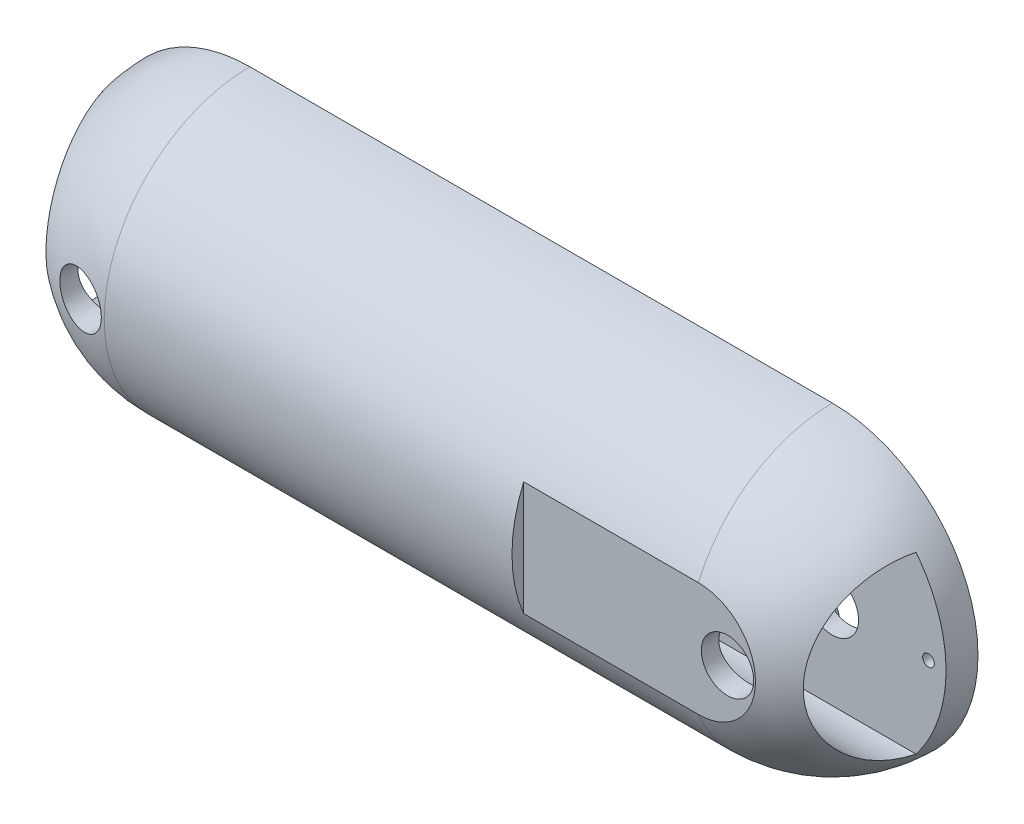
from build123d import *

# Parameters (mm, degrees)
REVOLVE1_ANGLE          = 180
SKETCH7_R               = 4.5
CUT_EXTRUDE2_DEPTH      = 26
CUT_EXTRUDE5_DEPTH      = 26
CUT_EXTRUDE5_DEPTH_BACK = 126
SKETCH12_W              = 5
SKETCH12_H              = 50
CUT_EXTRUDE6_DEPTH      = 20
CUT_EXTRUDE6_DEPTH_BACK = 30
CUT_EXTRUDE7_START      = -5
CUT_EXTRUDE7_DEPTH      = 2
SKETCH14_R              = 1
CUT_EXTRUDE8_DEPTH      = 5


with BuildPart() as part:
    # Sketch5 → Revolve1 (revolve)
    with BuildSketch(Plane.XY):
        with BuildLine():
            Line((0, 0), (-100, 0))
            Line((-100, 0), (-125, 0))
            ThreePointArc((-125, 0), (-117.67766953, 17.67766953), (-100, 25))
            Line((-100, 25), (0, 25))
            ThreePointArc((0, 25), (17.67766953, 17.67766953), (25, 0))
            Line((25, 0), (0, 0))
        make_face()
    revolve(axis=Axis((-64.676616915, 0, 0), (1, 0, 0)), revolution_arc=REVOLVE1_ANGLE)

    # Sketch7 → Cut-Extrude2 (cut, through all)
    with BuildSketch(Plane(origin=(0, 0, 0), x_dir=(-1, 0, 0), z_dir=(0, 0, -1))):
        with Locations((-5, 0)):
            Circle(SKETCH7_R)
        with Locations((105, 0)):
            Circle(SKETCH7_R)
    extrude(amount=-CUT_EXTRUDE2_DEPTH, mode=Mode.SUBTRACT)

    # Sketch10 → Cut-Extrude5 (cut, two sides)
    with BuildSketch(Plane(origin=(0, 0, 0), x_dir=(0, 0, -1), z_dir=(1, 0, 0))) as cut_extrude5_sk:
        with BuildLine():
            Line((-5, 15), (-5, -15))
            ThreePointArc((-5, -15), (-20, 0), (-5, 15))
        make_face()
    extrude(amount=CUT_EXTRUDE5_DEPTH, mode=Mode.SUBTRACT)
    extrude(cut_extrude5_sk.sketch, amount=-CUT_EXTRUDE5_DEPTH_BACK, mode=Mode.SUBTRACT)

    # Sketch12 → Cut-Extrude6 (cut, two sides)
    with BuildSketch(Plane(origin=(0, 0, 0), x_dir=(0, 0, -1), z_dir=(1, 0, 0))) as cut_extrude6_sk:
        with Locations((-25.5, 0)):
            Rectangle(SKETCH12_W, SKETCH12_H)
    extrude(amount=CUT_EXTRUDE6_DEPTH, mode=Mode.SUBTRACT)
    extrude(cut_extrude6_sk.sketch, amount=-CUT_EXTRUDE6_DEPTH_BACK, mode=Mode.SUBTRACT)

    # Sketch13 → Cut-Extrude7 (cut)
    with BuildSketch(Plane.XY.offset(5).offset(CUT_EXTRUDE7_START)):
        with BuildLine():
            Line((7.5, 16.5), (8.79175539, 6.456036683))
            ThreePointArc((8.79175539, 6.456036683), (9.53927005, 4.651376653), (11.34393008, 3.903861993))
            add(Edge.make_bspline(
                [(21.5, 2.5), (11.34393008, 3.903861993)],
                knots=[0, 0, 1, 1], degree=1))
            ThreePointArc((21.5, 2.5), (24, 0), (21.5, -2.5))
            Line((21.5, -2.5), (11.456036683, -3.79175539))
            ThreePointArc((11.456036683, -3.79175539), (9.651376653, -4.53927005), (8.903861993, -6.34393008))
            Line((8.903861993, -6.34393008), (7.5, -16.5))
            ThreePointArc((7.5, -16.5), (5, -19), (2.5, -16.5))
            Line((2.5, -16.5), (1.20824461, -6.456036683))
            ThreePointArc((1.20824461, -6.456036683), (0.46072995, -4.651376653), (-1.34393008, -3.903861993))
            Line((-1.34393008, -3.903861993), (-11.5, -2.5))
            ThreePointArc((-11.5, -2.5), (-14, 0), (-11.5, 2.5))
            Line((-11.5, 2.5), (-1.456036683, 3.79175539))
            ThreePointArc((-1.456036683, 3.79175539), (0.348623347, 4.53927005), (1.096138007, 6.34393008))
            Line((1.096138007, 6.34393008), (2.5, 16.5))
            ThreePointArc((2.5, 16.5), (5, 19), (7.5, 16.5))
        make_face()
        with BuildLine():
            Line((-102.5, 16.5), (-101.127521023, 6.403861993))
            ThreePointArc((-101.127521023, 6.403861993), (-100.395287976, 4.63609504), (-98.627521023, 3.903861993))
            add(Edge.make_bspline(
                [(-88.5, 2.5), (-98.627521023, 3.903861993)],
                knots=[0, 0, 1, 1], degree=1))
            ThreePointArc((-88.5, 2.5), (-86, 0), (-88.5, -2.5))
            Line((-88.5, -2.5), (-98.627521023, -3.79175539))
            ThreePointArc((-98.627521023, -3.79175539), (-100.395287976, -4.523988437), (-101.127521023, -6.29175539))
            Line((-101.127521023, -6.29175539), (-102.5, -16.5))
            ThreePointArc((-102.5, -16.5), (-105, -19), (-107.5, -16.5))
            Line((-107.5, -16.5), (-108.823138405, -6.29175539))
            ThreePointArc((-108.823138405, -6.29175539), (-109.555371452, -4.523988437), (-111.323138405, -3.79175539))
            Line((-111.323138405, -3.79175539), (-121.5, -2.5))
            ThreePointArc((-121.5, -2.5), (-124, 0), (-121.5, 2.5))
            Line((-121.5, 2.5), (-111.323138405, 3.903861993))
            ThreePointArc((-111.323138405, 3.903861993), (-109.555371452, 4.63609504), (-108.823138405, 6.403861993))
            Line((-108.823138405, 6.403861993), (-107.5, 16.5))
            ThreePointArc((-107.5, 16.5), (-105, 19), (-102.5, 16.5))
        make_face()
    extrude(amount=CUT_EXTRUDE7_DEPTH, mode=Mode.SUBTRACT)

    # Sketch14 → Cut-Extrude8 (cut)
    with BuildSketch(Plane(origin=(0, 0, 2), x_dir=(-1, 0, 0), z_dir=(0, 0, -1))):
        with Locations((-5, 16.5)):
            Circle(SKETCH14_R)
        with Locations((11.5, 0)):
            Circle(SKETCH14_R)
        with Locations((-5, -16.5)):
            Circle(SKETCH14_R)
        with Locations((-21.5, 0)):
            Circle(SKETCH14_R)
        with Locations((105, 16.5)):
            Circle(SKETCH14_R)
        with Locations((121.5, 0)):
            Circle(SKETCH14_R)
        with Locations((105, -16.5)):
            Circle(SKETCH14_R)
        with Locations((88.5, 0)):
            Circle(SKETCH14_R)
    extrude(amount=-CUT_EXTRUDE8_DEPTH, mode=Mode.SUBTRACT)


solid = part.part
